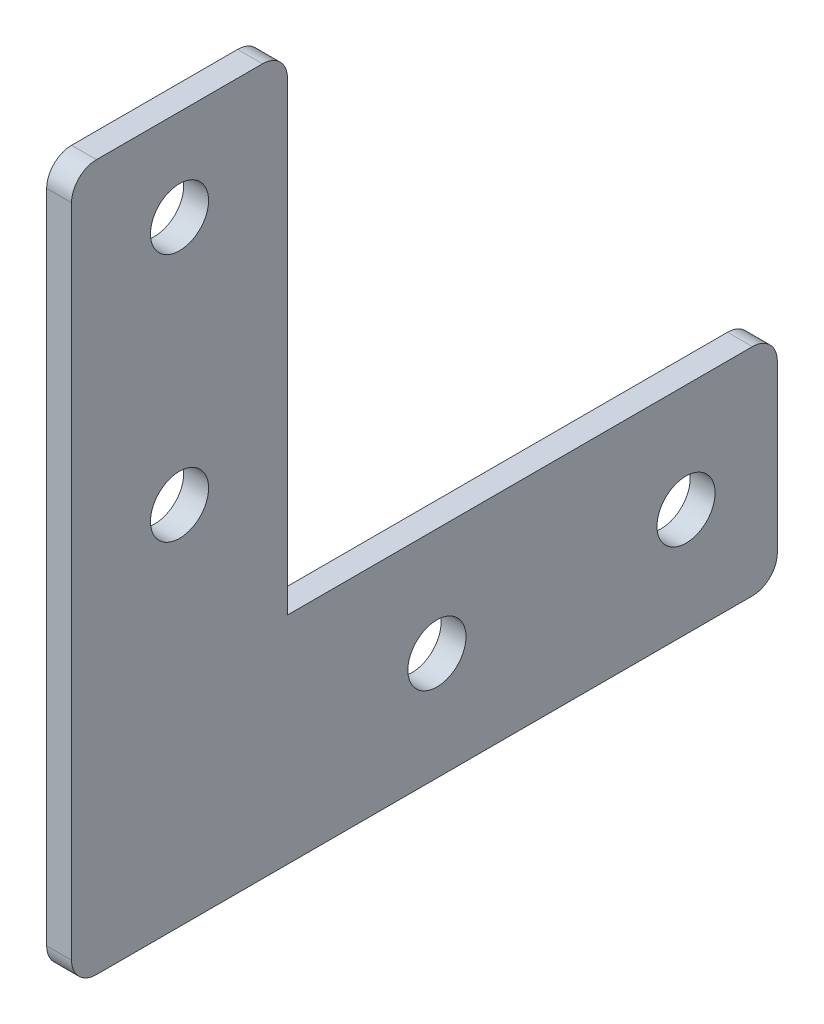
from build123d import *

# Parameters (mm, degrees)
SKETCH1_W           = 85
SKETCH1_H           = 85
BOSS_EXTRUDE1_DEPTH = 3
SKETCH2_W           = 59
SKETCH2_H           = 59
CUT_EXTRUDE1_DEPTH  = 121.245582039
DIAMETERHOLE1_D     = 7
FILLET1_R           = 3


with BuildPart() as part:
    # Sketch1 → Boss-Extrude1 (new body)
    with BuildSketch(Plane(origin=(0, 0, 0), x_dir=(0, 0, -1), z_dir=(1, 0, 0))):
        with Locations((42.5, 42.5)):
            Rectangle(SKETCH1_W, SKETCH1_H)
    extrude(amount=BOSS_EXTRUDE1_DEPTH)

    # Sketch2 → Cut-Extrude1 (cut, through all)
    with BuildSketch(Plane(origin=(0, 0, 0), x_dir=(0, 0, -1), z_dir=(1, 0, 0))):
        with Locations((55.5, 55.5)):
            Rectangle(SKETCH2_W, SKETCH2_H)
    extrude(amount=CUT_EXTRUDE1_DEPTH, mode=Mode.SUBTRACT)

    # DiameterHole1 (through all)
    with Locations(Plane(origin=(3, 0, 0), x_dir=(0, 0, -1), z_dir=(1, 0, 0))):
        with Locations((13, 74), (13, 44), (74, 13), (44, 13)):
            Hole(DIAMETERHOLE1_D / 2)

    # Fillet1
    fillet1_edges = [part.edges().sort_by_distance(p)[0] for p in [
        (1.5, 0, -85),
        (1.5, 0, 0),
        (1.5, 85, 0),
        (1.5, 26, -85),
        (1.5, 85, -26),
    ]]
    fillet(fillet1_edges, radius=FILLET1_R)


solid = part.part
